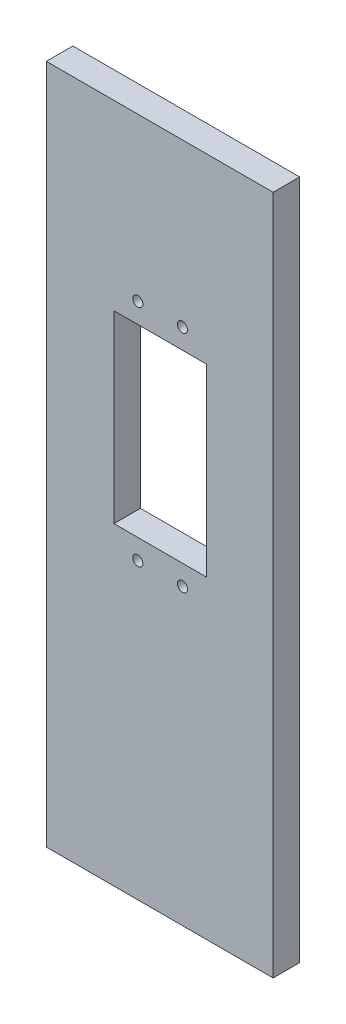
from build123d import *

# Parameters (mm, degrees)
SKETCH1_W           = 50.8
SKETCH1_H           = 152.4
BOSS_EXTRUDE1_DEPTH = 5.9436
SKETCH2_R           = 1.1303
SKETCH2_W           = 20.7
SKETCH2_H           = 41.3
CUT_EXTRUDE1_DEPTH  = 6.9436


with BuildPart() as part:
    # Sketch1 → Boss-Extrude1 (new body)
    with BuildSketch(Plane.XY):
        with Locations((25.4, 76.2)):
            Rectangle(SKETCH1_W, SKETCH1_H)
    extrude(amount=BOSS_EXTRUDE1_DEPTH)

    # Sketch2 → Cut-Extrude1 (cut, through all)
    with BuildSketch(Plane.XY.offset(5.9436)):
        with Locations((20.492131346, 116.1)):
            Circle(SKETCH2_R)
        with Locations((30.492131346, 116.1)):
            Circle(SKETCH2_R)
        with Locations((20.492131346, 65.8)):
            Circle(SKETCH2_R)
        with Locations((30.492131346, 65.8)):
            Circle(SKETCH2_R)
        with Locations((25.492131346, 90.95)):
            Rectangle(SKETCH2_W, SKETCH2_H)
    extrude(amount=-CUT_EXTRUDE1_DEPTH, mode=Mode.SUBTRACT)


solid = part.part
